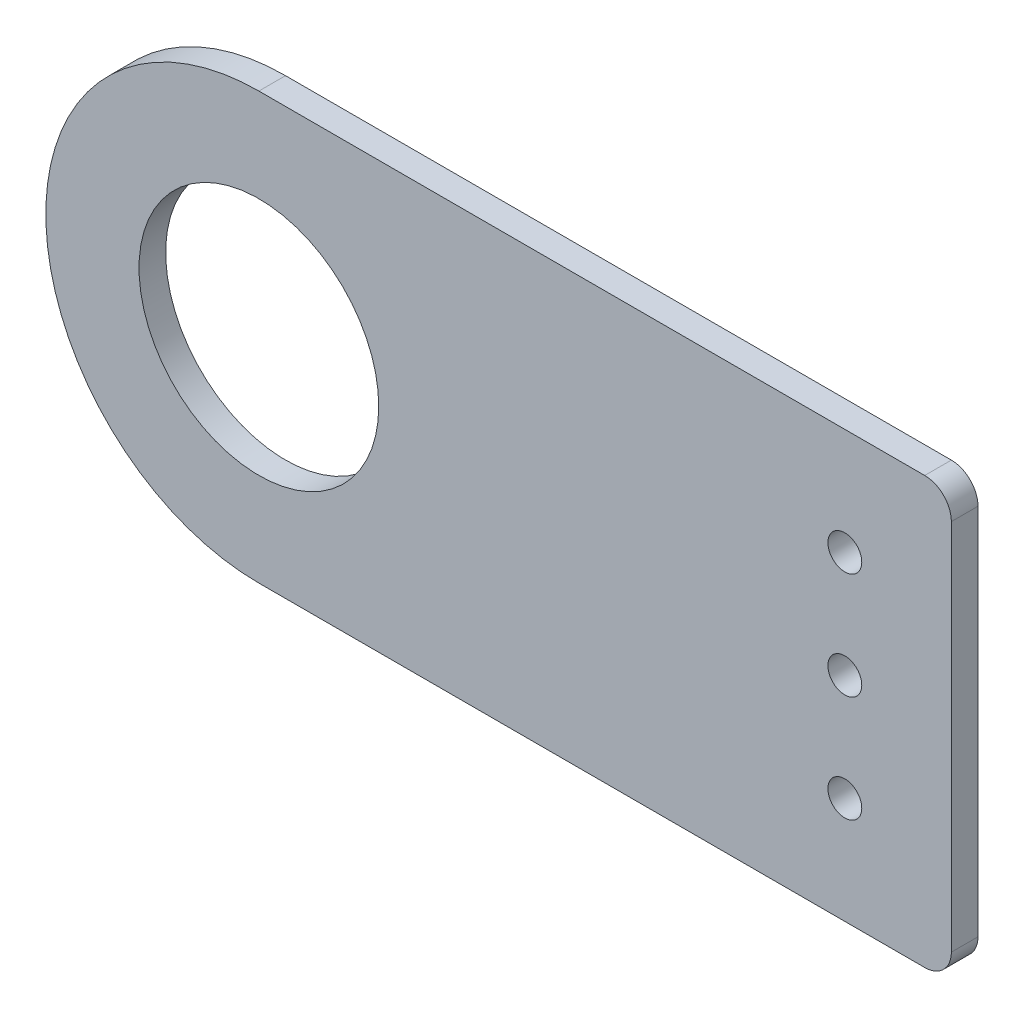
from build123d import *

# Parameters (mm, degrees)
SKETCH1_R           = 2.0193
SKETCH1_R_2         = 14.2875
BOSS_EXTRUDE1_DEPTH = 3.175
FILLET1_R           = 3.175


with BuildPart() as part:
    # Sketch1 → Boss-Extrude1 (new body)
    with BuildSketch(Plane.XY):
        with BuildLine():
            Line((12.7, -38.1), (12.7, 12.7))
            Line((12.7, 12.7), (-69.85, 12.7))
            ThreePointArc((-69.85, 12.7), (-95.25, -12.7), (-69.85, -38.1))
            Line((-69.85, -38.1), (12.7, -38.1))
        make_face()
        Circle(SKETCH1_R, mode=Mode.SUBTRACT)
        with Locations((0, -12.7)):
            Circle(SKETCH1_R, mode=Mode.SUBTRACT)
        with Locations((0, -25.4)):
            Circle(SKETCH1_R, mode=Mode.SUBTRACT)
        with Locations((-69.85, -12.7)):
            Circle(SKETCH1_R_2, mode=Mode.SUBTRACT)
    extrude(amount=BOSS_EXTRUDE1_DEPTH)

    # Fillet1
    fillet1_edges = [part.edges().sort_by_distance(p)[0] for p in [
        (12.7, 12.7, 1.5875),
        (12.7, -38.1, 1.5875),
    ]]
    fillet(fillet1_edges, radius=FILLET1_R)


solid = part.part
